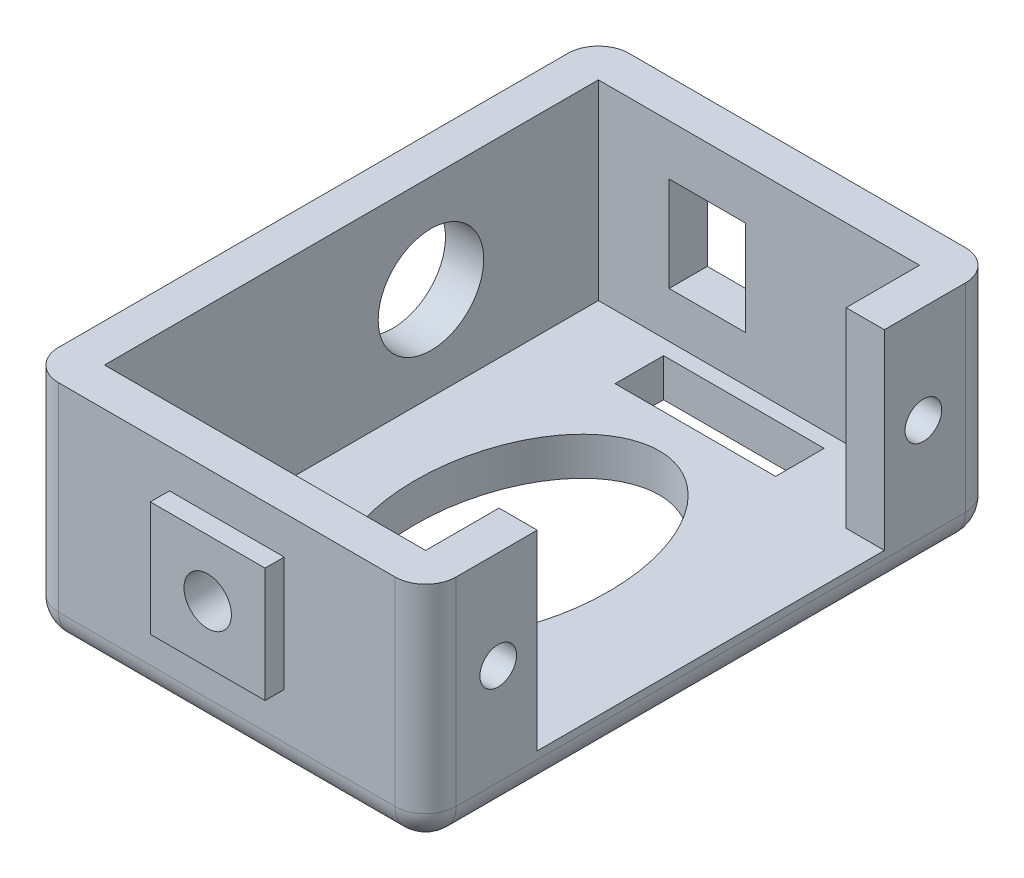
from build123d import *

# Parameters (mm, degrees)
BOSS_EXTRUDE1_DEPTH = 15
SKETCH2_W           = 32.3
SKETCH2_H           = 2.5
BOSS_EXTRUDE2_DEPTH = 23.5
SKETCH3_W           = 5
SKETCH3_H           = 6.2
CUT_EXTRUDE1_DEPTH  = 12.5
CUT_EXTRUDE2_REACH  = 28
SKETCH4_R           = 3.45
SKETCH5_R           = 1.2
CUT_EXTRUDE3_DEPTH  = 2.5
CUT_EXTRUDE4_REACH  = 39.3
SKETCH6_R           = 1.55
FILLET2_R           = 2
CUT_EXTRUDE6_REACH  = 4.5
SKETCH8_RX          = 9.634046057
SKETCH8_RY          = 6.312870092
SKETCH8_W           = 10.5
SKETCH8_H           = 3.175
SKETCH7_W           = 7.5
SKETCH7_H           = 7.5
SKETCH7_R           = 1.55
BOSS_EXTRUDE3_DEPTH = 1.25


with BuildPart() as part:
    # Sketch1 → Boss-Extrude1 (new body)
    with BuildSketch(Plane(origin=(0, 0, 0), x_dir=(1, 0, 0), z_dir=(0, 1, 0))):
        Polygon((0, 29.994099724), (-26, 29.994099724), (-26, -7.305900276), (0, -7.305900276), (0, -0.005900276), (-2.5, -0.005900276), (-2.5, -4.805900276), (-23.5, -4.805900276), (-23.5, 27.494099724), (-2.5, 27.494099724), (-2.5, 22.694099724), (0, 22.694099724), align=None)
    extrude(amount=BOSS_EXTRUDE1_DEPTH)

    # Sketch2 → Boss-Extrude2 (add, through all)
    with BuildSketch(Plane(origin=(-23.5, 0, 0), x_dir=(0, 0, -1), z_dir=(1, 0, 0))):
        with Locations((11.344099724, 1.25)):
            Rectangle(SKETCH2_W, SKETCH2_H)
    extrude(amount=BOSS_EXTRUDE2_DEPTH)

    # Sketch3 → Cut-Extrude1 (cut)
    with BuildSketch(Plane(origin=(0, 0, -29.994099724), x_dir=(-1, 0, 0), z_dir=(0, 0, -1))):
        with Locations((16.375, 8.6)):
            Rectangle(SKETCH3_W, SKETCH3_H)
    extrude(amount=-CUT_EXTRUDE1_DEPTH, mode=Mode.SUBTRACT)

    # Sketch4 → Cut-Extrude2 (cut, up to next)
    with BuildSketch(Plane.ZY.offset(26), mode=Mode.PRIVATE) as cut_extrude2_sk1:
        with Locations((-16.544099724, 8.6)):
            Circle(SKETCH4_R)
    cut_extrude2_tool1 = extrude(cut_extrude2_sk1.sketch, amount=-CUT_EXTRUDE2_REACH, mode=Mode.PRIVATE) & part.part
    add(cut_extrude2_tool1.solids().sort_by_distance((-26, 8.6, -16.5441))[0], mode=Mode.SUBTRACT)

    # Sketch5 → Cut-Extrude3 (cut)
    with BuildSketch(Plane(origin=(0, 0, 0), x_dir=(0, 0, -1), z_dir=(1, 0, 0))):
        with Locations((-2.555900276, 8.6)):
            Circle(SKETCH5_R)
    cut_extrude3 = extrude(amount=-CUT_EXTRUDE3_DEPTH, mode=Mode.SUBTRACT)

    # Mirror1: Cut-Extrude3 across plane
    add(cut_extrude3.mirror(Plane.XY.offset(-11.344099724)), mode=Mode.SUBTRACT)

    # Sketch6 → Cut-Extrude4 (cut, up to next)
    with BuildSketch(Plane.XY.offset(7.305900276), mode=Mode.PRIVATE) as cut_extrude4_sk1:
        with Locations((-13, 8.75)):
            Circle(SKETCH6_R)
    cut_extrude4_tool1 = extrude(cut_extrude4_sk1.sketch, amount=-CUT_EXTRUDE4_REACH, mode=Mode.PRIVATE) & part.part
    add(cut_extrude4_tool1.solids().sort_by_distance((-13, 8.75, 7.3059))[0], mode=Mode.SUBTRACT)

    # Fillet2
    fillet2_edges = [part.edges().sort_by_distance(p)[0] for p in [
        (0, 0, -11.344099724),
        (-13, 0, 7.305900276),
        (-26, 0, -11.344099724),
        (-13, 0, -29.994099724),
        (0, 7.5, 7.305900276),
        (-26, 7.5, 7.305900276),
        (-26, 7.5, -29.994099724),
        (0, 7.5, -29.994099724),
    ]]
    fillet(fillet2_edges, radius=FILLET2_R)

    # Sketch8 → Cut-Extrude6 (cut, up to next)
    with BuildSketch(Plane(origin=(0, 2.5, 0), x_dir=(1, 0, 0), z_dir=(0, 1, 0)), mode=Mode.PRIVATE) as cut_extrude6_sk1:
        with Locations(Location((-13, 11.344099724), (0, 0, 90))):
            Ellipse(SKETCH8_RX, SKETCH8_RY)
    cut_extrude6_tool1 = extrude(cut_extrude6_sk1.sketch, amount=-CUT_EXTRUDE6_REACH, mode=Mode.PRIVATE) & part.part
    add(cut_extrude6_tool1.solids().sort_by_distance((-13, 2.5, -11.3441))[0], mode=Mode.SUBTRACT)
    # Sketch8 → Cut-Extrude6 (cut, up to next)
    with BuildSketch(Plane(origin=(0, 2.5, 0), x_dir=(1, 0, 0), z_dir=(0, 1, 0)), mode=Mode.PRIVATE) as cut_extrude6_sk2:
        with Locations((-13, -2.231384095)):
            Rectangle(SKETCH8_W, SKETCH8_H)
    cut_extrude6_tool2 = extrude(cut_extrude6_sk2.sketch, amount=-CUT_EXTRUDE6_REACH, mode=Mode.PRIVATE) & part.part
    add(cut_extrude6_tool2.solids().sort_by_distance((-13, 2.5, 2.231384))[0], mode=Mode.SUBTRACT)
    # Sketch8 → Cut-Extrude6 (cut, up to next)
    with BuildSketch(Plane(origin=(0, 2.5, 0), x_dir=(1, 0, 0), z_dir=(0, 1, 0)), mode=Mode.PRIVATE) as cut_extrude6_sk3:
        with Locations((-13, 24.919583542)):
            Rectangle(SKETCH8_W, SKETCH8_H)
    cut_extrude6_tool3 = extrude(cut_extrude6_sk3.sketch, amount=-CUT_EXTRUDE6_REACH, mode=Mode.PRIVATE) & part.part
    add(cut_extrude6_tool3.solids().sort_by_distance((-13, 2.5, -24.919584))[0], mode=Mode.SUBTRACT)

    # Sketch7 → Boss-Extrude3 (add)
    with BuildSketch(Plane.XY.offset(7.305900276)):
        with Locations((-13, 8.75)):
            Rectangle(SKETCH7_W, SKETCH7_H)
        with Locations((-13, 8.75)):
            Circle(SKETCH7_R, mode=Mode.SUBTRACT)
    extrude(amount=BOSS_EXTRUDE3_DEPTH)


solid = part.part
